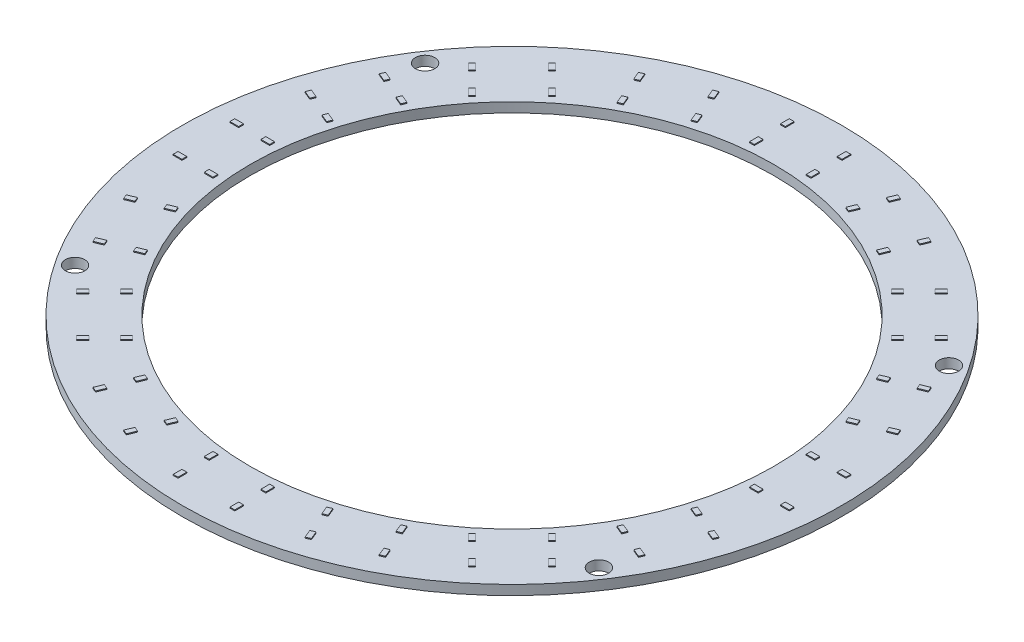
from build123d import *

# Parameters (mm, degrees)
SKIZZE1_R                       = 34
SKIZZE1_R_2                     = 27
RING_DEPTH                      = 1
SKIZZE5_W                       = 0.5
SKIZZE5_H                       = 0.9
SKIZZE5_W_2                     = 0.9
SKIZZE5_H_2                     = 0.5
AUFSATZ_LINEAR_AUSTRAGEN4_DEPTH = 0.1
SKIZZE6_R                       = 1
SCHNITT_LINEAR_AUSTRAGEN1_DEPTH = 2
SKIZZE7_W                       = 1.5
SKIZZE7_H                       = 3
AUFSATZ_LINEAR_AUSTRAGEN5_DEPTH = 0.001


with BuildPart() as part:
    # Skizze1 → Ring (new body)
    with BuildSketch(Plane(origin=(0, 0, 0), x_dir=(1, 0, 0), z_dir=(0, 1, 0))):
        Circle(SKIZZE1_R)
        Circle(SKIZZE1_R_2, mode=Mode.SUBTRACT)
    extrude(amount=RING_DEPTH)

    # Skizze5 → Aufsatz-Linear austragen4 (add)
    with BuildSketch(Plane(origin=(0, 1, 0), x_dir=(1, 0, 0), z_dir=(0, 1, 0))):
        with Locations((-2.925, 31.325)):
            Rectangle(SKIZZE5_W, SKIZZE5_H)
        with Locations((2.925, 31.325)):
            Rectangle(SKIZZE5_W, SKIZZE5_H)
        with Locations((2.925, 28.125)):
            Rectangle(SKIZZE5_W, SKIZZE5_H)
        with Locations((-2.925, 28.125)):
            Rectangle(SKIZZE5_W, SKIZZE5_H)
        Polygon((9.226448548, 30.571292043), (9.688388314, 30.379950327), (9.343973225, 29.548458748), (8.882033459, 29.739800464), align=None)
        Polygon((14.631143813, 28.332593964), (14.286728724, 27.501102385), (14.74866849, 27.309760669), (15.093083579, 28.141252248), align=None)
        Polygon((13.524081506, 24.353346164), (13.06214174, 24.544687881), (13.406556829, 25.37617946), (13.868496596, 25.184837744), align=None)
        Polygon((8.119386241, 26.592044244), (8.46380133, 27.423535823), (8.001861564, 27.614877539), (7.657446475, 26.78338596), align=None)
        Polygon((20.223253942, 24.713382002), (20.576807333, 24.359828612), (19.940411229, 23.723432509), (19.586857839, 24.076985899), align=None)
        Polygon((24.359828612, 20.576807333), (23.723432509, 19.940411229), (24.076985899, 19.586857839), (24.713382002, 20.223253942), align=None)
        Polygon((21.8142442, 17.324116139), (21.460690809, 17.67766953), (22.097086912, 18.314065633), (22.450640303, 17.960512242), align=None)
        Polygon((17.67766953, 21.460690809), (18.314065633, 22.097086912), (17.960512242, 22.450640303), (17.324116139, 21.8142442), align=None)
        Polygon((28.141252248, 15.093083579), (28.332593964, 14.631143813), (27.501102385, 14.286728724), (27.309760669, 14.74866849), align=None)
        Polygon((30.379950327, 9.688388314), (29.548458748, 9.343973225), (29.739800464, 8.882033459), (30.571292043, 9.226448548), align=None)
        Polygon((26.78338596, 7.657446475), (26.592044244, 8.119386241), (27.423535823, 8.46380133), (27.614877539, 8.001861564), align=None)
        Polygon((24.544687881, 13.06214174), (25.37617946, 13.406556829), (25.184837744, 13.868496596), (24.353346164, 13.524081506), align=None)
        with Locations((31.325, 2.925)):
            Rectangle(SKIZZE5_W_2, SKIZZE5_H_2)
        with Locations((31.325, -2.925)):
            Rectangle(SKIZZE5_W_2, SKIZZE5_H_2)
        with Locations((28.125, -2.925)):
            Rectangle(SKIZZE5_W_2, SKIZZE5_H_2)
        with Locations((28.125, 2.925)):
            Rectangle(SKIZZE5_W_2, SKIZZE5_H_2)
        Polygon((30.571292043, -9.226448548), (30.379950327, -9.688388314), (29.548458748, -9.343973225), (29.739800464, -8.882033459), align=None)
        Polygon((28.332593964, -14.631143813), (27.501102385, -14.286728724), (27.309760669, -14.74866849), (28.141252248, -15.093083579), align=None)
        Polygon((24.353346164, -13.524081506), (24.544687881, -13.06214174), (25.37617946, -13.406556829), (25.184837744, -13.868496596), align=None)
        Polygon((26.592044244, -8.119386241), (27.423535823, -8.46380133), (27.614877539, -8.001861564), (26.78338596, -7.657446475), align=None)
        Polygon((24.713382002, -20.223253942), (24.359828612, -20.576807333), (23.723432509, -19.940411229), (24.076985899, -19.586857839), align=None)
        Polygon((20.576807333, -24.359828612), (19.940411229, -23.723432509), (19.586857839, -24.076985899), (20.223253942, -24.713382002), align=None)
        Polygon((17.324116139, -21.8142442), (17.67766953, -21.460690809), (18.314065633, -22.097086912), (17.960512242, -22.450640303), align=None)
        Polygon((21.460690809, -17.67766953), (22.097086912, -18.314065633), (22.450640303, -17.960512242), (21.8142442, -17.324116139), align=None)
        Polygon((15.093083579, -28.141252248), (14.631143813, -28.332593964), (14.286728724, -27.501102385), (14.74866849, -27.309760669), align=None)
        Polygon((9.688388314, -30.379950327), (9.343973225, -29.548458748), (8.882033459, -29.739800464), (9.226448548, -30.571292043), align=None)
        Polygon((7.657446475, -26.78338596), (8.119386241, -26.592044244), (8.46380133, -27.423535823), (8.001861564, -27.614877539), align=None)
        Polygon((13.06214174, -24.544687881), (13.406556829, -25.37617946), (13.868496596, -25.184837744), (13.524081506, -24.353346164), align=None)
        with Locations((2.925, -31.325)):
            Rectangle(SKIZZE5_W, SKIZZE5_H)
        with Locations((-2.925, -31.325)):
            Rectangle(SKIZZE5_W, SKIZZE5_H)
        with Locations((-2.925, -28.125)):
            Rectangle(SKIZZE5_W, SKIZZE5_H)
        with Locations((2.925, -28.125)):
            Rectangle(SKIZZE5_W, SKIZZE5_H)
        Polygon((-9.226448548, -30.571292043), (-9.688388314, -30.379950327), (-9.343973225, -29.548458748), (-8.882033459, -29.739800464), align=None)
        Polygon((-14.631143813, -28.332593964), (-14.286728724, -27.501102385), (-14.74866849, -27.309760669), (-15.093083579, -28.141252248), align=None)
        Polygon((-13.524081506, -24.353346164), (-13.06214174, -24.544687881), (-13.406556829, -25.37617946), (-13.868496596, -25.184837744), align=None)
        Polygon((-8.119386241, -26.592044244), (-8.46380133, -27.423535823), (-8.001861564, -27.614877539), (-7.657446475, -26.78338596), align=None)
        Polygon((-20.223253942, -24.713382002), (-20.576807333, -24.359828612), (-19.940411229, -23.723432509), (-19.586857839, -24.076985899), align=None)
        Polygon((-24.359828612, -20.576807333), (-23.723432509, -19.940411229), (-24.076985899, -19.586857839), (-24.713382002, -20.223253942), align=None)
        Polygon((-21.8142442, -17.324116139), (-21.460690809, -17.67766953), (-22.097086912, -18.314065633), (-22.450640303, -17.960512242), align=None)
        Polygon((-17.67766953, -21.460690809), (-18.314065633, -22.097086912), (-17.960512242, -22.450640303), (-17.324116139, -21.8142442), align=None)
        Polygon((-28.141252248, -15.093083579), (-28.332593964, -14.631143813), (-27.501102385, -14.286728724), (-27.309760669, -14.74866849), align=None)
        Polygon((-30.379950327, -9.688388314), (-29.548458748, -9.343973225), (-29.739800464, -8.882033459), (-30.571292043, -9.226448548), align=None)
        Polygon((-26.78338596, -7.657446475), (-26.592044244, -8.119386241), (-27.423535823, -8.46380133), (-27.614877539, -8.001861564), align=None)
        Polygon((-24.544687881, -13.06214174), (-25.37617946, -13.406556829), (-25.184837744, -13.868496596), (-24.353346164, -13.524081506), align=None)
        with Locations((-31.325, -2.925)):
            Rectangle(SKIZZE5_W_2, SKIZZE5_H_2)
        with Locations((-31.325, 2.925)):
            Rectangle(SKIZZE5_W_2, SKIZZE5_H_2)
        with Locations((-28.125, 2.925)):
            Rectangle(SKIZZE5_W_2, SKIZZE5_H_2)
        with Locations((-28.125, -2.925)):
            Rectangle(SKIZZE5_W_2, SKIZZE5_H_2)
        Polygon((-30.571292043, 9.226448548), (-30.379950327, 9.688388314), (-29.548458748, 9.343973225), (-29.739800464, 8.882033459), align=None)
        Polygon((-28.332593964, 14.631143813), (-27.501102385, 14.286728724), (-27.309760669, 14.74866849), (-28.141252248, 15.093083579), align=None)
        Polygon((-24.353346164, 13.524081506), (-24.544687881, 13.06214174), (-25.37617946, 13.406556829), (-25.184837744, 13.868496596), align=None)
        Polygon((-26.592044244, 8.119386241), (-27.423535823, 8.46380133), (-27.614877539, 8.001861564), (-26.78338596, 7.657446475), align=None)
        Polygon((-24.713382002, 20.223253942), (-24.359828612, 20.576807333), (-23.723432509, 19.940411229), (-24.076985899, 19.586857839), align=None)
        Polygon((-20.576807333, 24.359828612), (-19.940411229, 23.723432509), (-19.586857839, 24.076985899), (-20.223253942, 24.713382002), align=None)
        Polygon((-17.324116139, 21.8142442), (-17.67766953, 21.460690809), (-18.314065633, 22.097086912), (-17.960512242, 22.450640303), align=None)
        Polygon((-21.460690809, 17.67766953), (-22.097086912, 18.314065633), (-22.450640303, 17.960512242), (-21.8142442, 17.324116139), align=None)
        Polygon((-15.093083579, 28.141252248), (-14.631143813, 28.332593964), (-14.286728724, 27.501102385), (-14.74866849, 27.309760669), align=None)
        Polygon((-9.688388314, 30.379950327), (-9.343973225, 29.548458748), (-8.882033459, 29.739800464), (-9.226448548, 30.571292043), align=None)
        Polygon((-7.657446475, 26.78338596), (-8.119386241, 26.592044244), (-8.46380133, 27.423535823), (-8.001861564, 27.614877539), align=None)
        Polygon((-13.06214174, 24.544687881), (-13.406556829, 25.37617946), (-13.868496596, 25.184837744), (-13.524081506, 24.353346164), align=None)
    extrude(amount=AUFSATZ_LINEAR_AUSTRAGEN4_DEPTH)

    # Skizze6 → Schnitt-Linear austragen1 (cut, through all)
    with BuildSketch(Plane(origin=(0, 1, 0), x_dir=(1, 0, 0), z_dir=(0, 1, 0))):
        with Locations((-27.0227624, 18.056032573)):
            Circle(SKIZZE6_R)
        with Locations((-27.0227624, -18.056032573)):
            Circle(SKIZZE6_R)
        with Locations((27.0227624, 18.056032573)):
            Circle(SKIZZE6_R)
        with Locations((27.0227624, -18.056032573)):
            Circle(SKIZZE6_R)
    extrude(amount=-SCHNITT_LINEAR_AUSTRAGEN1_DEPTH, mode=Mode.SUBTRACT)

    # Skizze7 → Aufsatz-Linear austragen5 (add)
    with BuildSketch(Plane(origin=(0, 0, 0), x_dir=(-1, 0, 0), z_dir=(0, -1, 0))):
        with Locations((-4, -31.25)):
            Rectangle(SKIZZE7_W, SKIZZE7_H)
        with Locations((4, -31.25)):
            Rectangle(SKIZZE7_W, SKIZZE7_H)
        with Locations((1.333333333, -31.25)):
            Rectangle(SKIZZE7_W, SKIZZE7_H)
        with Locations((-1.333333333, -31.25)):
            Rectangle(SKIZZE7_W, SKIZZE7_H)
    extrude(amount=AUFSATZ_LINEAR_AUSTRAGEN5_DEPTH)


solid = part.part
